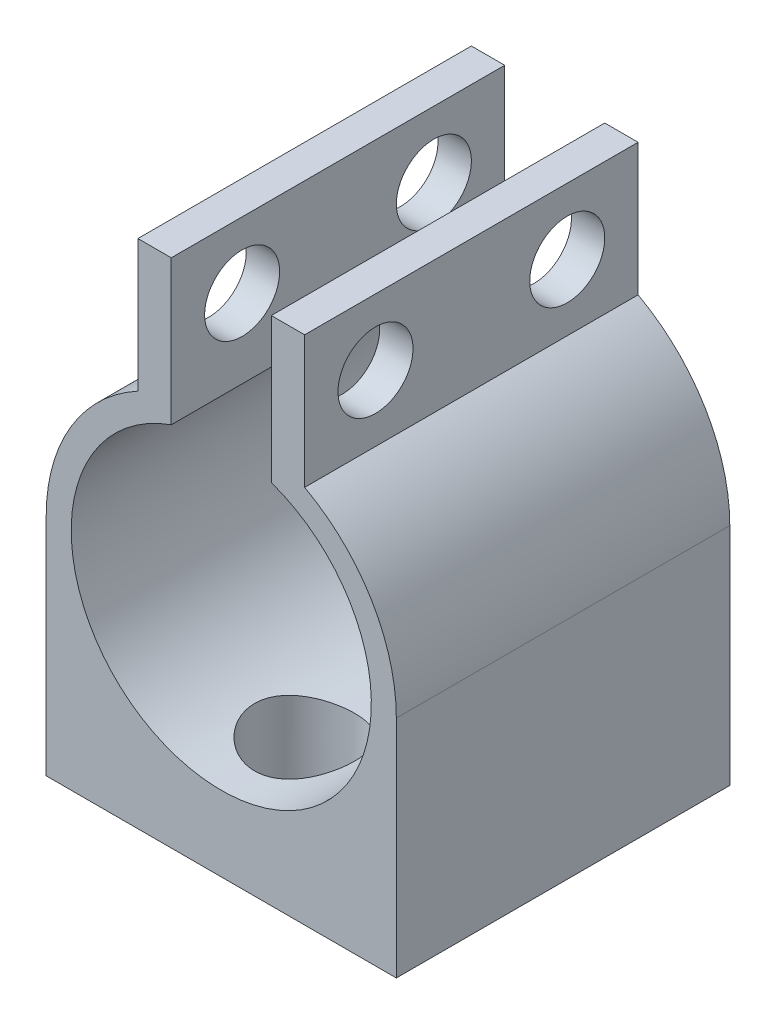
from build123d import *

# Parameters (mm, degrees)
BOSS_EXTRUDE1_DEPTH = 20
SKETCH3_R           = 2.25
CUT_EXTRUDE1_DEPTH  = 16.5
SKETCH5_R           = 2.125
CUT_EXTRUDE2_DEPTH  = 31.659519334
CUT_EXTRUDE6_START  = -6
SKETCH6_R           = 3
CUT_EXTRUDE6_DEPTH  = 44.5


with BuildPart() as part:
    # Sketch1 → Boss-Extrude1 (new body)
    with BuildSketch(Plane.XY):
        with BuildLine():
            Line((-3, 8.485281374), (-3, 17.159519334))
            Line((-3, 17.159519334), (-5, 17.159519334))
            Line((-5, 17.159519334), (-5, 9.233092656))
            ThreePointArc((-5, 9.233092656), (-9.020809276, 5.373546315), (-10.5, 0))
            Line((-10.5, 0), (-10.5, -13.5))
            Line((-10.5, -13.5), (10.5, -13.5))
            Line((10.5, -13.5), (10.5, 0))
            ThreePointArc((10.5, 0), (9.020809276, 5.373546315), (5, 9.233092656))
            Line((5, 9.233092656), (5, 17.159519334))
            Line((5, 17.159519334), (3, 17.159519334))
            Line((3, 17.159519334), (3, 8.485281374))
            ThreePointArc((3, 8.485281374), (0, -9), (-3, 8.485281374))
        make_face()
    extrude(amount=BOSS_EXTRUDE1_DEPTH)

    # Sketch3 → Cut-Extrude1 (cut, through all)
    with BuildSketch(Plane(origin=(5, 0, 0), x_dir=(0, 0, -1), z_dir=(1, 0, 0))):
        with Locations((-15.75, 13.196305995)):
            Circle(SKETCH3_R)
        with Locations((-4.25, 13.196305995)):
            Circle(SKETCH3_R)
    extrude(amount=-CUT_EXTRUDE1_DEPTH, mode=Mode.SUBTRACT)

    # Sketch5 → Cut-Extrude2 (cut, through all)
    with BuildSketch(Plane.XZ.offset(13.5)):
        with Locations((0, 5)):
            Circle(SKETCH5_R)
        with Locations((0, 15)):
            Circle(SKETCH5_R)
    extrude(amount=-CUT_EXTRUDE2_DEPTH, mode=Mode.SUBTRACT)

    # Sketch6 → Cut-Extrude6 (cut)
    with BuildSketch(Plane.XZ.offset(13.5).offset(CUT_EXTRUDE6_START)):
        with Locations((0, 15)):
            Circle(SKETCH6_R)
        with Locations((0, 5)):
            Circle(SKETCH6_R)
    extrude(amount=CUT_EXTRUDE6_DEPTH, mode=Mode.SUBTRACT)


solid = part.part
